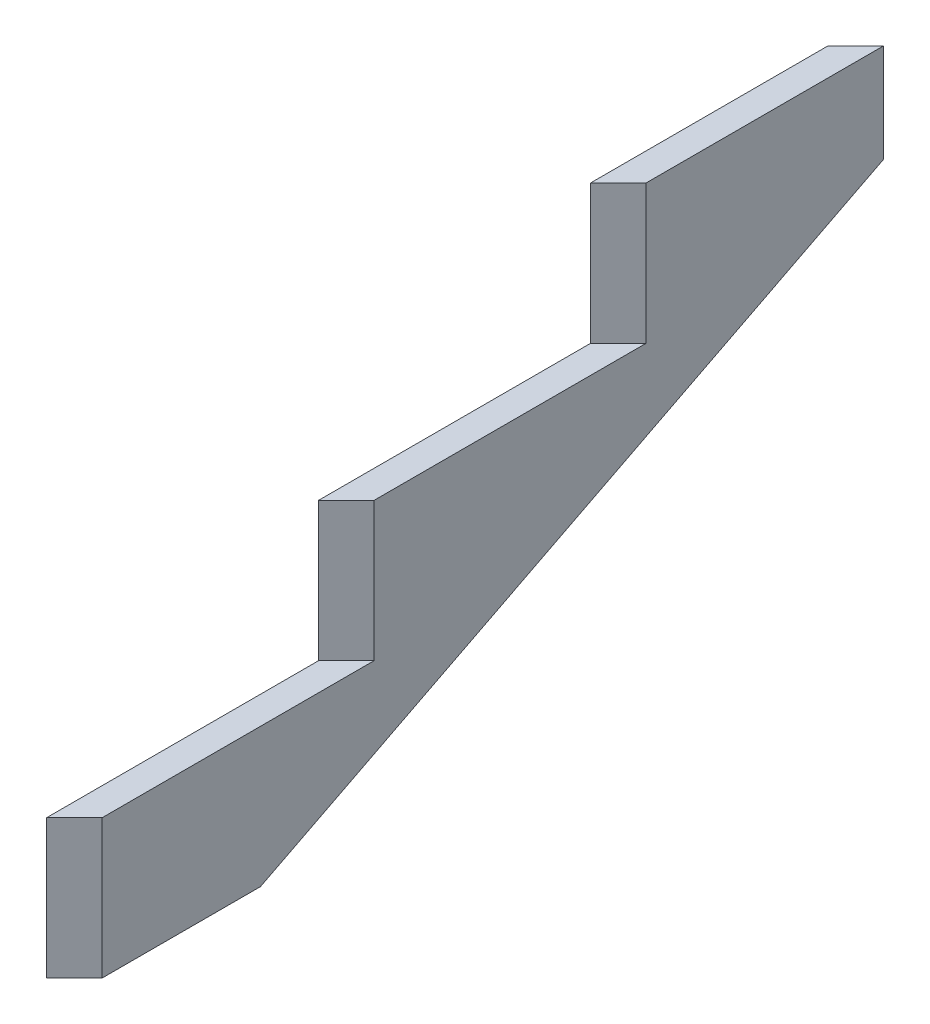
from build123d import *

# Parameters (mm, degrees)
BOSS_EXTRUDE2_DEPTH = 38.1
CUT_EXTRUDE4_DEPTH  = 190.5
CUT_EXTRUDE5_DEPTH  = 190.5
CUT_EXTRUDE6_REACH  = 573.5
CUT_EXTRUDE7_DEPTH  = 190.5


with BuildPart() as part:
    # Sketch1 → Boss-Extrude2 (new body)
    with BuildSketch(Plane(origin=(0, 0, 0), x_dir=(0, 0, -1), z_dir=(1, 0, 0))):
        Polygon((0, 0), (0, 190.5), (372.860234147, 190.5), (372.860234147, 381), (745.720468294, 381), (745.720468294, 571.5), (1109.600446319, 571.5), (1109.600446319, 436.526629402), (255.199284902, 0), align=None)
    extrude(amount=BOSS_EXTRUDE2_DEPTH)

    # Sketch3 → Cut-Extrude4 (cut)
    with BuildSketch(Plane(origin=(0, 381, 0), x_dir=(1, 0, 0), z_dir=(0, 1, 0))):
        Polygon((0, 372.860234147), (38.1, 410.960234147), (38.1, 372.860234147), align=None)
    extrude(amount=-CUT_EXTRUDE4_DEPTH, mode=Mode.SUBTRACT)

    # Sketch4 → Cut-Extrude5 (cut)
    with BuildSketch(Plane(origin=(0, 190.5, 0), x_dir=(1, 0, 0), z_dir=(0, 1, 0))):
        Polygon((0, 0), (38.1, 38.1), (38.1, 0), align=None)
    extrude(amount=-CUT_EXTRUDE5_DEPTH, mode=Mode.SUBTRACT)

    # Sketch2 → Cut-Extrude6 (cut, up to next)
    with BuildSketch(Plane(origin=(0, 571.5, 0), x_dir=(1, 0, 0), z_dir=(0, 1, 0)), mode=Mode.PRIVATE) as cut_extrude6_sk1:
        Polygon((0, 1071.500446319), (38.1, 1109.600446319), (0, 1109.600446319), align=None)
    cut_extrude6_tool1 = extrude(cut_extrude6_sk1.sketch, amount=-CUT_EXTRUDE6_REACH, mode=Mode.PRIVATE) & part.part
    add(cut_extrude6_tool1.solids().sort_by_distance((12.7, 571.5, -1096.900446))[0], mode=Mode.SUBTRACT)

    # Sketch2_5 → Cut-Extrude7 (cut)
    with BuildSketch(Plane(origin=(0, 571.5, 0), x_dir=(1, 0, 0), z_dir=(0, 1, 0))):
        Polygon((38.1, 745.720468294), (38.1, 783.820468294), (0, 745.720468294), align=None)
    extrude(amount=-CUT_EXTRUDE7_DEPTH, mode=Mode.SUBTRACT)


solid = part.part
